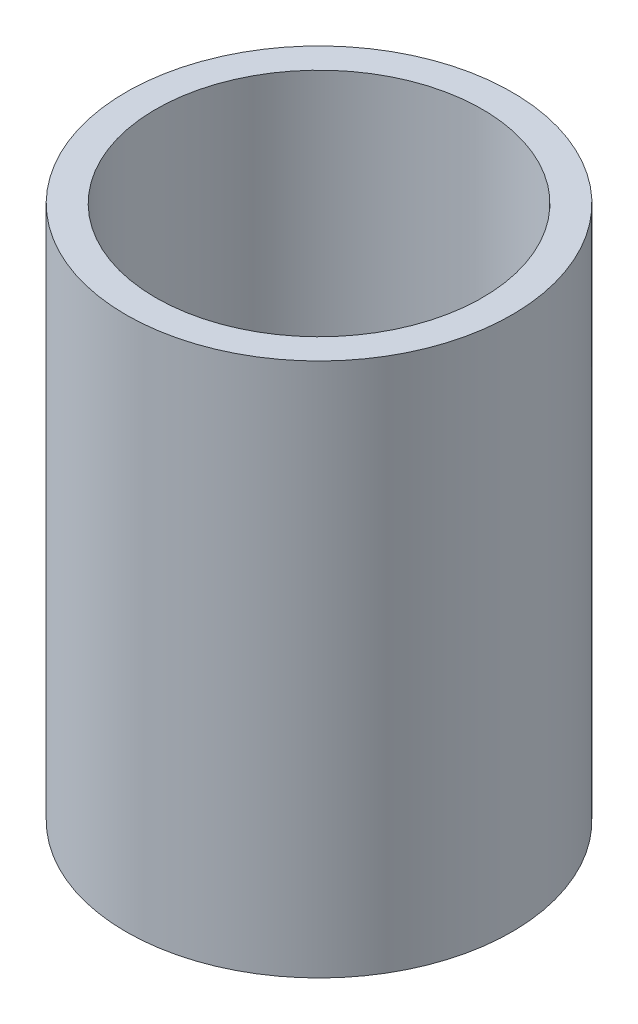
from build123d import *

# Parameters (mm, degrees)
SKETCH1_R           = 3.25
SKETCH1_R_2         = 2.75
BOSS_EXTRUDE1_DEPTH = 9


with BuildPart() as part:
    # Sketch1 → Boss-Extrude1 (new body)
    with BuildSketch(Plane(origin=(0, 0, 0), x_dir=(1, 0, 0), z_dir=(0, 1, 0))):
        Circle(SKETCH1_R)
        Circle(SKETCH1_R_2, mode=Mode.SUBTRACT)
    extrude(amount=BOSS_EXTRUDE1_DEPTH)


solid = part.part
